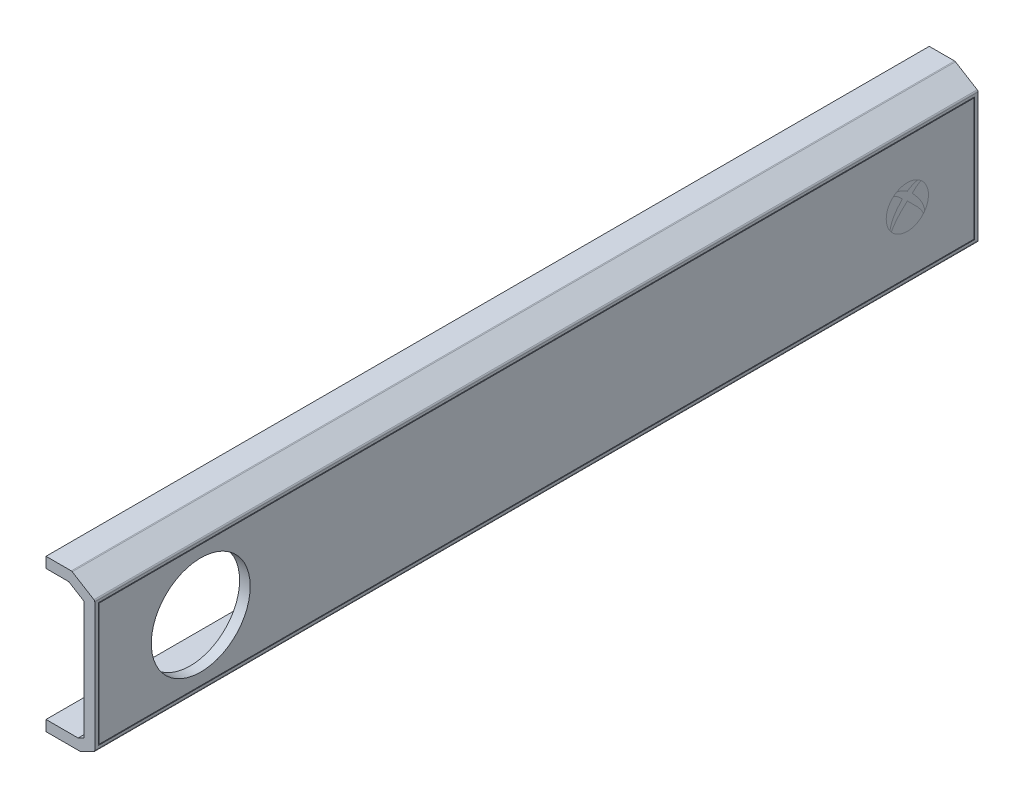
from build123d import *

# Parameters (mm, degrees)
BOSS_EXTRUDE1_DEPTH = 250
CUT_EXTRUDE1_REACH  = 45
SKETCH2_W           = 10.8
SKETCH2_H           = 114
SKETCH3_W           = 248
SKETCH3_H           = 35
SKETCH3_W_2         = 247.6
SKETCH3_H_2         = 34.6
CUT_EXTRUDE2_DEPTH  = 0.2
FILLET1_R           = 0.5
SKETCH4_R           = 14
CUT_EXTRUDE3_DEPTH  = 14.8


with BuildPart() as part:
    # Sketch1 → Boss-Extrude1 (new body)
    with BuildSketch(Plane.XY):
        Polygon((0, 3), (9.091796068, 3), (10.8, 3.854101966), (10.8, 37.323614418), (6.450873429, 40), (0, 40), (0, 43), (7.3, 43), (13.8, 39), (13.8, 2), (9.8, 0), (0, 0), align=None)
    extrude(amount=BOSS_EXTRUDE1_DEPTH)

    # Sketch2 → Cut-Extrude1 (cut, up to next)
    with BuildSketch(Plane.XZ, mode=Mode.PRIVATE) as cut_extrude1_sk1:
        with Locations((5.4, 125)):
            Rectangle(SKETCH2_W, SKETCH2_H)
    cut_extrude1_tool1 = extrude(cut_extrude1_sk1.sketch, amount=-CUT_EXTRUDE1_REACH, mode=Mode.PRIVATE) & part.part
    add(cut_extrude1_tool1.solids().sort_by_distance((5.4, 0, 125))[0], mode=Mode.SUBTRACT)

    # Sketch3 → Cut-Extrude2 (cut)
    with BuildSketch(Plane(origin=(13.8, 0, 0), x_dir=(0, 0, -1), z_dir=(1, 0, 0))):
        with Locations((-125, 20.5)):
            Rectangle(SKETCH3_W, SKETCH3_H)
        with Locations((-125, 20.5)):
            Rectangle(SKETCH3_W_2, SKETCH3_H_2, mode=Mode.SUBTRACT)
    extrude(amount=-CUT_EXTRUDE2_DEPTH, mode=Mode.SUBTRACT)

    # Fillet1
    fillet1_edges = [part.edges().sort_by_distance(p)[0] for p in [
        (13.8, 39, 125),
        (13.8, 2, 125),
        (9.8, 0, 216),
        (7.3, 43, 125),
        (9.8, 0, 34),
    ]]
    fillet(fillet1_edges, radius=FILLET1_R)

    # Sketch4 → Cut-Extrude3 (cut, through all)
    with BuildSketch(Plane(origin=(13.8, 0, 0), x_dir=(0, 0, -1), z_dir=(1, 0, 0))):
        with Locations((-220, 20.514809699)):
            Circle(SKETCH4_R)
    extrude(amount=-CUT_EXTRUDE3_DEPTH, mode=Mode.SUBTRACT)


solid = part.part
